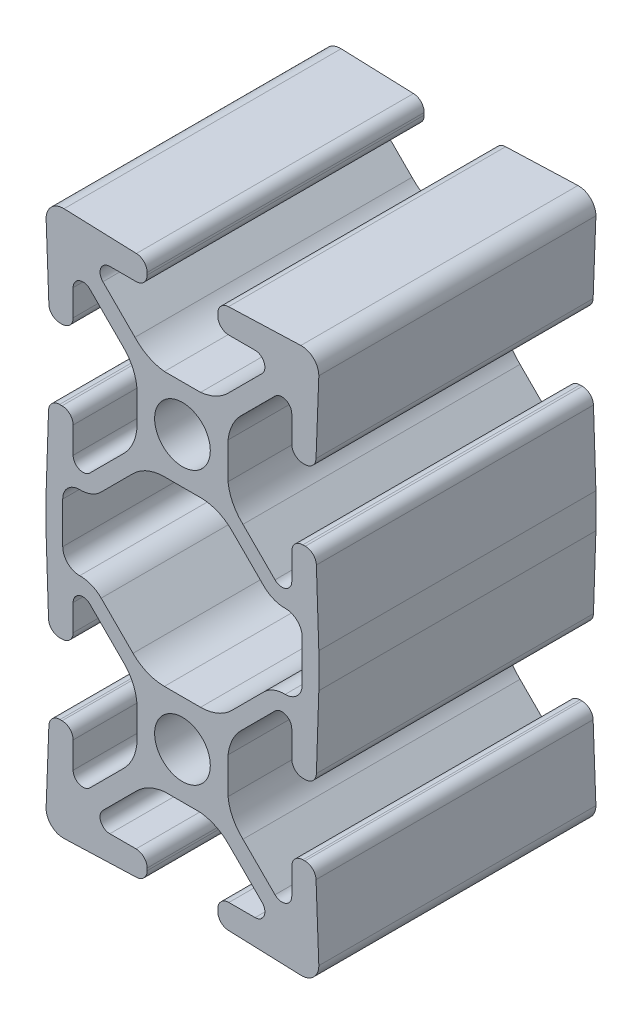
from build123d import *

# Parameters (mm, degrees)
SKETCH1_R      = 2.552699952
EXTRUDE1_DEPTH = 25.4


with BuildPart() as part:
    # Sketch1 → Extrude1 (new body)
    with BuildSketch(Plane.XY):
        with BuildLine():
            Line((-8.483605576, 7.293893252), (-5.545081932, 4.355385482))
            ThreePointArc((-5.545081932, 4.355385482), (-4.614735711, 3.132038282), (-4.177987221, 1.658480269))
            Line((-4.177987221, 1.658480269), (-4.177987221, -1.658480269))
            ThreePointArc((-4.177987221, -1.658480269), (-4.614735711, -3.132038282), (-5.545081932, -4.355385482))
            Line((-5.545081932, -4.355385482), (-8.483605576, -7.293893252))
            ThreePointArc((-8.483605576, -7.293893252), (-9.464416196, -7.488986523), (-10.019999931, -6.657495349))
            Line((-10.019999931, -6.657495349), (-10.019999685, -4.25451262))
            ThreePointArc((-10.019999685, -4.25451262), (-10.317579227, -3.536092054), (-11.035999792, -3.238512512))
            Line((-11.035999792, -3.238512512), (-11.226349864, -3.237859075))
            ThreePointArc((-11.226349864, -3.237859075), (-11.933208752, -3.520692129), (-12.24510272, -4.215217994))
            Line((-12.24510272, -4.215217994), (-12.499999765, -10.913485754))
            ThreePointArc((-12.499999765, -10.913485754), (-12.014686132, -12.056001152), (-10.855475092, -12.4999612))
            Line((-10.855475092, -12.4999612), (-4.22175692, -12.26151704))
            ThreePointArc((-4.22175692, -12.26151704), (-3.524602107, -11.952788933), (-3.238512512, -11.246042429))
            Line((-3.238512512, -11.246042429), (-3.238512512, -11.035999792))
            ThreePointArc((-3.238512512, -11.035999792), (-3.536092054, -10.317579227), (-4.25451262, -10.019999685))
            Line((-4.25451262, -10.019999685), (-6.657495349, -10.019999931))
            ThreePointArc((-6.657495349, -10.019999931), (-7.488986523, -9.464416196), (-7.293893252, -8.483605576))
            Line((-7.293893252, -8.483605576), (-4.355385482, -5.545081932))
            ThreePointArc((-4.355385482, -5.545081932), (-3.132038282, -4.614735711), (-1.658480269, -4.177987221))
            Line((-1.658480269, -4.177987221), (1.658480269, -4.177987221))
            ThreePointArc((1.658480269, -4.177987221), (3.132038282, -4.614735711), (4.355385482, -5.545081932))
            Line((4.355385482, -5.545081932), (7.293893252, -8.483605576))
            ThreePointArc((7.293893252, -8.483605576), (7.488986523, -9.464416196), (6.657495349, -10.019999931))
            Line((6.657495349, -10.019999931), (4.25451262, -10.019999685))
            ThreePointArc((4.25451262, -10.019999685), (3.536092054, -10.317579227), (3.238512512, -11.035999792))
            Line((3.238512512, -11.035999792), (3.238512512, -11.246042429))
            ThreePointArc((3.238512512, -11.246042429), (3.524602107, -11.952788933), (4.22175692, -12.26151704))
            Line((4.22175692, -12.26151704), (10.855475092, -12.4999612))
            ThreePointArc((10.855475092, -12.4999612), (12.014686132, -12.056001152), (12.499999765, -10.913485754))
            Line((12.499999765, -10.913485754), (12.24510272, -4.215217994))
            ThreePointArc((12.24510272, -4.215217994), (11.933208752, -3.520692129), (11.226349864, -3.237859075))
            Line((11.226349864, -3.237859075), (11.035999792, -3.238512512))
            ThreePointArc((11.035999792, -3.238512512), (10.317579227, -3.536092054), (10.019999685, -4.25451262))
            Line((10.019999685, -4.25451262), (10.019999931, -6.657495349))
            ThreePointArc((10.019999931, -6.657495349), (9.464416196, -7.488986523), (8.483605576, -7.293893252))
            Line((8.483605576, -7.293893252), (5.545081932, -4.355385482))
            ThreePointArc((5.545081932, -4.355385482), (4.614735711, -3.132038282), (4.177987221, -1.658480269))
            Line((4.177987221, -1.658480269), (4.177987221, 1.658480269))
            ThreePointArc((4.177987221, 1.658480269), (4.614735711, 3.132038282), (5.545081932, 4.355385482))
            Line((5.545081932, 4.355385482), (8.483605576, 7.293893252))
            ThreePointArc((8.483605576, 7.293893252), (9.464416196, 7.488986523), (10.019999931, 6.657495349))
            Line((10.019999931, 6.657495349), (10.019999685, 4.25451262))
            ThreePointArc((10.019999685, 4.25451262), (10.317579227, 3.536092054), (11.035999792, 3.238512512))
            Line((11.035999792, 3.238512512), (11.258353132, 3.237749214))
            ThreePointArc((11.258353132, 3.237749214), (11.966958292, 3.522261588), (12.277278698, 4.219950495))
            Line((12.277278698, 4.219950495), (12.499999765, 10.912499795))
            Line((12.499999765, 10.912499795), (12.499999765, 14.087499735))
            Line((12.499999765, 14.087499735), (12.277278698, 20.780049035))
            ThreePointArc((12.277278698, 20.780049035), (11.966958292, 21.477737942), (11.258353132, 21.762250316))
            Line((11.258353132, 21.762250316), (11.035999792, 21.761487018))
            ThreePointArc((11.035999792, 21.761487018), (10.317579227, 21.463907476), (10.019999685, 20.74548691))
            Line((10.019999685, 20.74548691), (10.019999931, 18.34250418))
            ThreePointArc((10.019999931, 18.34250418), (9.464416196, 17.511013007), (8.483605576, 17.706106278))
            Line((8.483605576, 17.706106278), (5.545081932, 20.644614048))
            ThreePointArc((5.545081932, 20.644614048), (4.614735711, 21.867961248), (4.177987221, 23.341519261))
            Line((4.177987221, 23.341519261), (4.177987221, 26.658479799))
            ThreePointArc((4.177987221, 26.658479799), (4.614735711, 28.132037812), (5.545081932, 29.355385011))
            Line((5.545081932, 29.355385011), (8.483605576, 32.293892782))
            ThreePointArc((8.483605576, 32.293892782), (9.464416196, 32.488986052), (10.019999931, 31.657494879))
            Line((10.019999931, 31.657494879), (10.019999685, 29.25451215))
            ThreePointArc((10.019999685, 29.25451215), (10.317579227, 28.536091584), (11.035999792, 28.238512042))
            Line((11.035999792, 28.238512042), (11.226349864, 28.237858605))
            ThreePointArc((11.226349864, 28.237858605), (11.933208752, 28.520691659), (12.24510272, 29.215217524))
            Line((12.24510272, 29.215217524), (12.499999765, 35.913485284))
            ThreePointArc((12.499999765, 35.913485284), (12.014686132, 37.056000682), (10.855475092, 37.499960729))
            Line((10.855475092, 37.499960729), (4.22175692, 37.261516569))
            ThreePointArc((4.22175692, 37.261516569), (3.524602107, 36.952788463), (3.238512512, 36.246041959))
            Line((3.238512512, 36.246041959), (3.238512512, 36.035999322))
            ThreePointArc((3.238512512, 36.035999322), (3.536092054, 35.317578756), (4.25451262, 35.019999214))
            Line((4.25451262, 35.019999214), (6.657495349, 35.019999461))
            ThreePointArc((6.657495349, 35.019999461), (7.488986523, 34.464415726), (7.293893252, 33.483605106))
            Line((7.293893252, 33.483605106), (4.355385482, 30.545081462))
            ThreePointArc((4.355385482, 30.545081462), (3.132038282, 29.614735241), (1.658480269, 29.177986751))
            Line((1.658480269, 29.177986751), (-1.658480269, 29.177986751))
            ThreePointArc((-1.658480269, 29.177986751), (-3.132038282, 29.614735241), (-4.355385482, 30.545081462))
            Line((-4.355385482, 30.545081462), (-7.293893252, 33.483605106))
            ThreePointArc((-7.293893252, 33.483605106), (-7.488986523, 34.464415726), (-6.657495349, 35.019999461))
            Line((-6.657495349, 35.019999461), (-4.25451262, 35.019999214))
            ThreePointArc((-4.25451262, 35.019999214), (-3.536092054, 35.317578756), (-3.238512512, 36.035999322))
            Line((-3.238512512, 36.035999322), (-3.238512512, 36.246041959))
            ThreePointArc((-3.238512512, 36.246041959), (-3.524602107, 36.952788463), (-4.22175692, 37.261516569))
            Line((-4.22175692, 37.261516569), (-10.855475092, 37.499960729))
            ThreePointArc((-10.855475092, 37.499960729), (-12.014686132, 37.056000682), (-12.499999765, 35.913485284))
            Line((-12.499999765, 35.913485284), (-12.24510272, 29.215217524))
            ThreePointArc((-12.24510272, 29.215217524), (-11.933208752, 28.520691659), (-11.226349864, 28.237858605))
            Line((-11.226349864, 28.237858605), (-11.035999792, 28.238512042))
            ThreePointArc((-11.035999792, 28.238512042), (-10.317579227, 28.536091584), (-10.019999685, 29.25451215))
            Line((-10.019999685, 29.25451215), (-10.019999931, 31.657494879))
            ThreePointArc((-10.019999931, 31.657494879), (-9.464416196, 32.488986052), (-8.483605576, 32.293892782))
            Line((-8.483605576, 32.293892782), (-5.545081932, 29.355385011))
            ThreePointArc((-5.545081932, 29.355385011), (-4.614735711, 28.132037812), (-4.177987221, 26.658479799))
            Line((-4.177987221, 26.658479799), (-4.177987221, 23.341519261))
            ThreePointArc((-4.177987221, 23.341519261), (-4.614735711, 21.867961248), (-5.545081932, 20.644614048))
            Line((-5.545081932, 20.644614048), (-8.483605576, 17.706106278))
            ThreePointArc((-8.483605576, 17.706106278), (-9.464416196, 17.511013007), (-10.019999931, 18.34250418))
            Line((-10.019999931, 18.34250418), (-10.019999685, 20.74548691))
            ThreePointArc((-10.019999685, 20.74548691), (-10.317579227, 21.463907476), (-11.035999792, 21.761487018))
            Line((-11.035999792, 21.761487018), (-11.258353132, 21.762250316))
            ThreePointArc((-11.258353132, 21.762250316), (-11.966958292, 21.477737942), (-12.277278698, 20.780049035))
            Line((-12.277278698, 20.780049035), (-12.499999765, 14.087499735))
            Line((-12.499999765, 14.087499735), (-12.499999765, 10.912499795))
            Line((-12.499999765, 10.912499795), (-12.277278698, 4.219950495))
            ThreePointArc((-12.277278698, 4.219950495), (-11.966958292, 3.522261588), (-11.258353132, 3.237749214))
            Line((-11.258353132, 3.237749214), (-11.035999792, 3.238512512))
            ThreePointArc((-11.035999792, 3.238512512), (-10.317579227, 3.536092054), (-10.019999685, 4.25451262))
            Line((-10.019999685, 4.25451262), (-10.019999931, 6.657495349))
            ThreePointArc((-10.019999931, 6.657495349), (-9.464416196, 7.488986523), (-8.483605576, 7.293893252))
        make_face()
        Circle(SKETCH1_R, mode=Mode.SUBTRACT)
        with Locations((0, 24.99999953)):
            Circle(SKETCH1_R, mode=Mode.SUBTRACT)
        with BuildLine():
            Line((-4.532162174, 5.36830524), (-7.449420439, 8.285579265))
            ThreePointArc((-7.449420439, 8.285579265), (-8.351141741, 8.889360855), (-9.418419027, 9.085760214))
            ThreePointArc((-9.418419027, 9.085760214), (-10.5176918, 9.519951543), (-10.975999794, 10.60939017))
            Line((-10.975999794, 10.60939017), (-10.975999794, 14.39060936))
            ThreePointArc((-10.975999794, 14.39060936), (-10.5176918, 15.480047987), (-9.418419027, 15.914239316))
            ThreePointArc((-9.418419027, 15.914239316), (-8.351141741, 16.110638675), (-7.449420439, 16.714420265))
            Line((-7.449420439, 16.714420265), (-4.532162174, 19.63169429))
            ThreePointArc((-4.532162174, 19.63169429), (-3.213705709, 20.512658734), (-1.658480269, 20.822012308))
            Line((-1.658480269, 20.822012308), (1.658480269, 20.822012308))
            ThreePointArc((1.658480269, 20.822012308), (3.213705709, 20.512658734), (4.532162174, 19.63169429))
            Line((4.532162174, 19.63169429), (7.449420439, 16.714420265))
            ThreePointArc((7.449420439, 16.714420265), (8.351141741, 16.110638675), (9.418419027, 15.914239316))
            ThreePointArc((9.418419027, 15.914239316), (10.5176918, 15.480047987), (10.975999794, 14.39060936))
            Line((10.975999794, 14.39060936), (10.975999794, 10.60939017))
            ThreePointArc((10.975999794, 10.60939017), (10.5176918, 9.519951543), (9.418419027, 9.085760214))
            ThreePointArc((9.418419027, 9.085760214), (8.351141741, 8.889360855), (7.449420439, 8.285579265))
            Line((7.449420439, 8.285579265), (4.532162174, 5.36830524))
            ThreePointArc((4.532162174, 5.36830524), (3.213705709, 4.487340795), (1.658480269, 4.177987221))
            Line((1.658480269, 4.177987221), (-1.658480269, 4.177987221))
            ThreePointArc((-1.658480269, 4.177987221), (-3.213705709, 4.487340795), (-4.532162174, 5.36830524))
        make_face(mode=Mode.SUBTRACT)
    extrude(amount=EXTRUDE1_DEPTH)


solid = part.part
